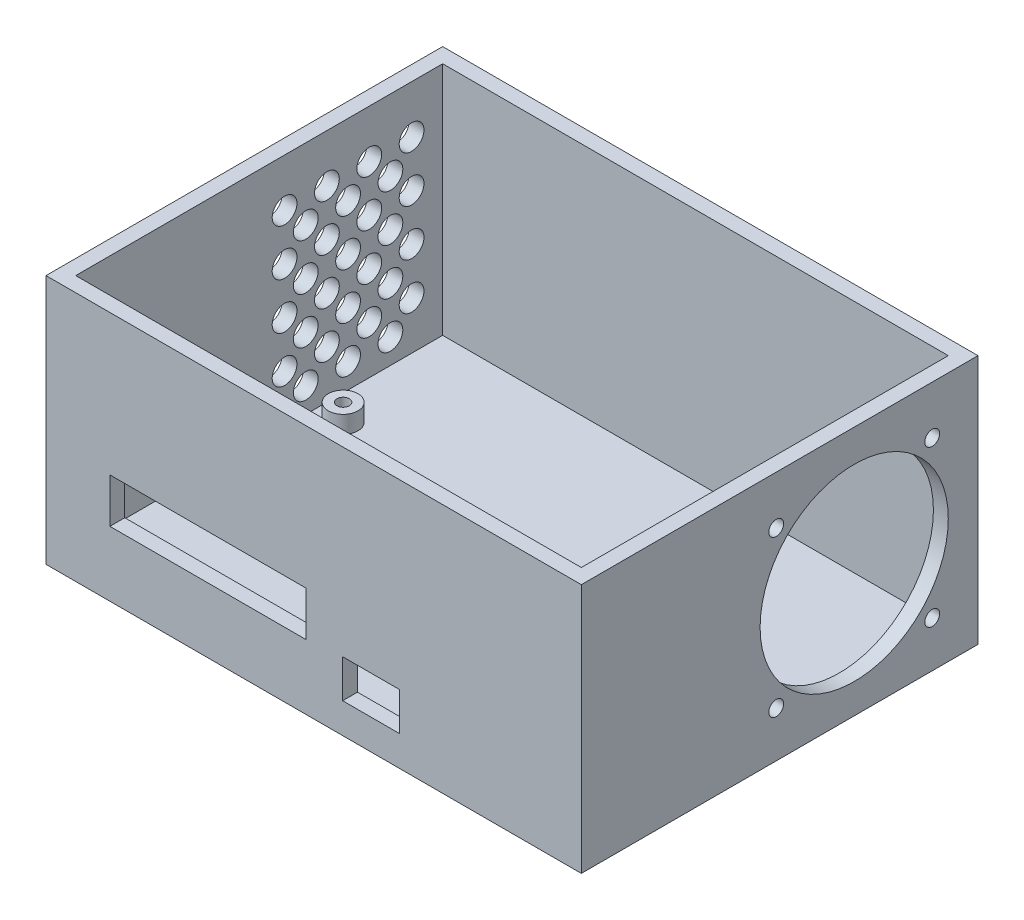
from build123d import *

# Parameters (mm, degrees)
SKETCH1_W                 = 78.1
SKETCH1_H                 = 55.9
BOSS_EXTRUDE1_DEPTH       = 3
SKETCH2_R                 = 1.25
CUT_EXTRUDE1_DEPTH        = 68
SKETCH4_W                 = 82.1
SKETCH4_H                 = 59.9
SKETCH4_W_2               = 78.1
SKETCH4_H_2               = 55.9
BOSS_EXTRUDE3_DEPTH       = 3
SKETCH6_R                 = 3
SKETCH6_R_2               = 1.25
BOSS_EXTRUDE4_DEPTH       = 3.5
SKETCH7_W                 = 82.1
SKETCH7_H                 = 16.2
BOSS_EXTRUDE5_DEPTH       = 3
SKETCH8_W                 = 82.1
SKETCH8_H                 = 50.5
BOSS_EXTRUDE6_DEPTH       = 3
BOSS_EXTRUDE7_DEPTH       = 20
SKETCH12_W                = 79.1
SKETCH12_H                = 50.5
BOSS_EXTRUDE8_DEPTH       = 3
SKETCH17_W                = 105.1
SKETCH17_H                = 50.5
BOSS_EXTRUDE13_DEPTH      = 1
BOSS_EXTRUDE13_DEPTH_BACK = 2
SKETCH18_W                = 11.5
SKETCH18_H                = 7.7
SKETCH18_W_2              = 39.6
SKETCH18_H_2              = 9
CUT_EXTRUDE4_DEPTH        = 9
SKETCH19_W                = 80.1
SKETCH19_H                = 50.5
BOSS_EXTRUDE14_DEPTH      = 3
SKETCH20_R                = 19
SKETCH20_R_2              = 1.5
CUT_EXTRUDE5_DEPTH        = 3
SKETCH22_R                = 2.5
CUT_EXTRUDE6_DEPTH        = 3


with BuildPart() as part:
    # Sketch1 → Boss-Extrude1 (new body)
    with BuildSketch(Plane(origin=(0, 0, 0), x_dir=(1, 0, 0), z_dir=(0, 1, 0))):
        Rectangle(SKETCH1_W, SKETCH1_H)
    extrude(amount=BOSS_EXTRUDE1_DEPTH)

    # Sketch2 → Cut-Extrude1 (cut)
    with BuildSketch(Plane(origin=(0, 3, 0), x_dir=(1, 0, 0), z_dir=(0, 1, 0))):
        with Locations((-35.9, 20.9)):
            Circle(SKETCH2_R)
        with Locations((-35.9, -24.8)):
            Circle(SKETCH2_R)
        with Locations((35.9, -24.8)):
            Circle(SKETCH2_R)
        with Locations((35.9, 24.8)):
            Circle(SKETCH2_R)
    extrude(amount=-CUT_EXTRUDE1_DEPTH, mode=Mode.SUBTRACT)

    # Sketch4 → Boss-Extrude3 (add)
    with BuildSketch(Plane(origin=(0, 0, 0), x_dir=(-1, 0, 0), z_dir=(0, -1, 0))):
        Rectangle(SKETCH4_W, SKETCH4_H)
        Rectangle(SKETCH4_W_2, SKETCH4_H_2, mode=Mode.SUBTRACT)
    extrude(amount=-BOSS_EXTRUDE3_DEPTH)

    # Sketch6 → Boss-Extrude4 (add)
    with BuildSketch(Plane(origin=(0, 3, 0), x_dir=(1, 0, 0), z_dir=(0, 1, 0))):
        with Locations((-35.9, 20.9)):
            Circle(SKETCH6_R)
        with Locations((-35.9, 20.9)):
            Circle(SKETCH6_R_2, mode=Mode.SUBTRACT)
        with Locations((35.9, 24.8)):
            Circle(SKETCH6_R)
        with Locations((35.9, 24.8)):
            Circle(SKETCH6_R_2, mode=Mode.SUBTRACT)
        with Locations((35.9, -24.8)):
            Circle(SKETCH6_R)
        with Locations((35.9, -24.8)):
            Circle(SKETCH6_R_2, mode=Mode.SUBTRACT)
        with Locations((-35.9, -24.8)):
            Circle(SKETCH6_R)
        with Locations((-35.9, -24.8)):
            Circle(SKETCH6_R_2, mode=Mode.SUBTRACT)
    extrude(amount=BOSS_EXTRUDE4_DEPTH)

    # Sketch7 → Boss-Extrude5 (add)
    with BuildSketch(Plane(origin=(0, 0, 0), x_dir=(-1, 0, 0), z_dir=(0, -1, 0))):
        with Locations((0, 38.05)):
            Rectangle(SKETCH7_W, SKETCH7_H)
    extrude(amount=-BOSS_EXTRUDE5_DEPTH)

    # Sketch8 → Boss-Extrude6 (add)
    with BuildSketch(Plane(origin=(0, 0, -46.15), x_dir=(-1, 0, 0), z_dir=(0, 0, -1))):
        with Locations((0, 25.25)):
            Rectangle(SKETCH8_W, SKETCH8_H)
    extrude(amount=BOSS_EXTRUDE6_DEPTH)

    # Sketch10 → Boss-Extrude7 (add)
    with BuildSketch(Plane(origin=(41.05, 0, 0), x_dir=(0, 0, -1), z_dir=(1, 0, 0))):
        Polygon((49.15, 50.5), (46.15, 50.5), (46.15, 3), (-29.95, 3), (-29.95, 0), (49.15, 0), align=None)
    extrude(amount=BOSS_EXTRUDE7_DEPTH)

    # Sketch12 → Boss-Extrude8 (add)
    with BuildSketch(Plane.ZY.offset(41.05)):
        with Locations((-9.6, 25.25)):
            Rectangle(SKETCH12_W, SKETCH12_H)
    extrude(amount=BOSS_EXTRUDE8_DEPTH)

    # Sketch17 → Boss-Extrude13 (add, two sides)
    with BuildSketch(Plane.XY.offset(29.95)) as boss_extrude13_sk:
        with Locations((8.5, 25.25)):
            Rectangle(SKETCH17_W, SKETCH17_H)
    extrude(amount=BOSS_EXTRUDE13_DEPTH)
    extrude(boss_extrude13_sk.sketch, amount=-BOSS_EXTRUDE13_DEPTH_BACK)

    # Sketch18 → Cut-Extrude4 (cut)
    with BuildSketch(Plane(origin=(0, 0, 27.95), x_dir=(-1, 0, 0), z_dir=(0, 0, -1))):
        with Locations((-21.6, 9.95)):
            Rectangle(SKETCH18_W, SKETCH18_H)
        with Locations((11.35, 17.6)):
            Rectangle(SKETCH18_W_2, SKETCH18_H_2)
    extrude(amount=-CUT_EXTRUDE4_DEPTH, mode=Mode.SUBTRACT)

    # Sketch19 → Boss-Extrude14 (add)
    with BuildSketch(Plane(origin=(61.05, 0, 0), x_dir=(0, 0, -1), z_dir=(1, 0, 0))):
        with Locations((9.1, 25.25)):
            Rectangle(SKETCH19_W, SKETCH19_H)
    extrude(amount=BOSS_EXTRUDE14_DEPTH)

    # Sketch20 → Cut-Extrude5 (cut)
    with BuildSketch(Plane.ZY.offset(-61.05)):
        with Locations((-24.15, 25)):
            Circle(SKETCH20_R)
        with Locations((-8.4, 40.75)):
            Circle(SKETCH20_R_2)
        with Locations((-39.9, 40.75)):
            Circle(SKETCH20_R_2)
        with Locations((-8.4, 9.25)):
            Circle(SKETCH20_R_2)
        with Locations((-39.9, 9.25)):
            Circle(SKETCH20_R_2)
    extrude(amount=-CUT_EXTRUDE5_DEPTH, mode=Mode.SUBTRACT)

    # Sketch22 → Cut-Extrude6 (cut)
    with BuildSketch(Plane(origin=(-41.05, 0, 0), x_dir=(0, 0, -1), z_dir=(1, 0, 0))):
        with Locations((14.225, 12.6875)):
            Circle(SKETCH22_R)
        with Locations((14.225, 22.0625)):
            Circle(SKETCH22_R)
        with Locations((18.5, 17.375)):
            Circle(SKETCH22_R)
        with Locations((22.775, 22.0625)):
            Circle(SKETCH22_R)
        with Locations((22.775, 12.6875)):
            Circle(SKETCH22_R)
        with Locations((14.225, 31.4375)):
            Circle(SKETCH22_R)
        with Locations((18.5, 26.75)):
            Circle(SKETCH22_R)
        with Locations((22.775, 31.4375)):
            Circle(SKETCH22_R)
        with Locations((18.5, 36.125)):
            Circle(SKETCH22_R)
        with Locations((14.225, 40.8125)):
            Circle(SKETCH22_R)
        with Locations((22.775, 40.8125)):
            Circle(SKETCH22_R)
        with Locations((27.05, 36.125)):
            Circle(SKETCH22_R)
        with Locations((31.325, 40.8125)):
            Circle(SKETCH22_R)
        with Locations((39.875, 40.8125)):
            Circle(SKETCH22_R)
        with Locations((35.6, 36.125)):
            Circle(SKETCH22_R)
        with Locations((39.875, 31.4375)):
            Circle(SKETCH22_R)
        with Locations((31.325, 31.4375)):
            Circle(SKETCH22_R)
        with Locations((27.05, 26.75)):
            Circle(SKETCH22_R)
        with Locations((31.325, 22.0625)):
            Circle(SKETCH22_R)
        with Locations((39.875, 22.0625)):
            Circle(SKETCH22_R)
        with Locations((35.6, 26.75)):
            Circle(SKETCH22_R)
        with Locations((27.05, 17.375)):
            Circle(SKETCH22_R)
        with Locations((31.325, 12.6875)):
            Circle(SKETCH22_R)
        with Locations((39.875, 12.6875)):
            Circle(SKETCH22_R)
        with Locations((35.6, 17.375)):
            Circle(SKETCH22_R)
        with Locations((18.5, 8)):
            Circle(SKETCH22_R)
        with Locations((27.05, 8)):
            Circle(SKETCH22_R)
        with Locations((35.6, 8)):
            Circle(SKETCH22_R)
    extrude(amount=-CUT_EXTRUDE6_DEPTH, mode=Mode.SUBTRACT)


solid = part.part
